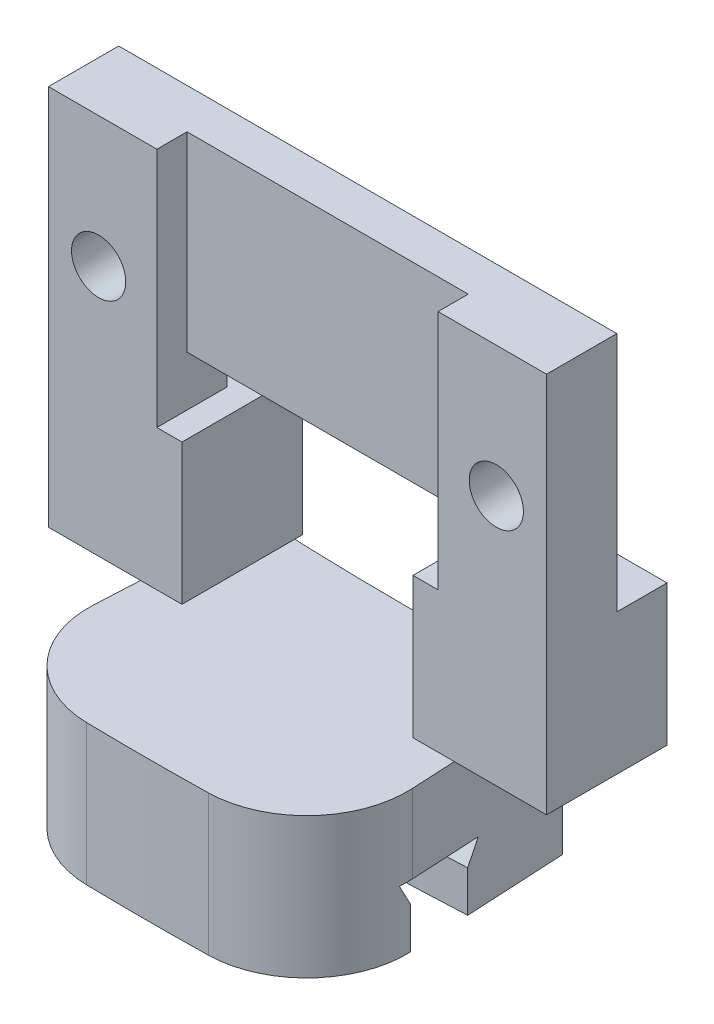
from build123d import *

# Parameters (mm, degrees)
MAIN_DEPTH            = 6
SKETCH8_R             = 1.35
HOLES_DEPTH           = 7
SKETCH12_W            = 14
SKETCH12_H            = 12
COMPONENTHOLES2_DEPTH = 1.5
SKETCH17_W            = 14
SKETCH17_H            = 2.5
HOLESCABLES_DEPTH     = 5.5
SKETCH16_W            = 2.5
SKETCH16_H            = 12
FIXEXTRUSION_DEPTH    = 25.8
SUPPORT_ANGLE         = 6
FILLET1_R             = 5


with BuildPart() as part:
    # Sketch7 → Main (new body)
    with BuildSketch(Plane.XY.offset(143)):
        Polygon((-12.4, 0), (-5.75, 0), (-5.75, 7), (5.75, 7), (5.75, 0), (12.4, 0), (12.4, 19), (-12.4, 19), align=None)
    extrude(amount=MAIN_DEPTH)

    # Sketch8 → Holes (cut, through all)
    with BuildSketch(Plane.XY.offset(149)):
        with Locations((-9.9, 12.5)):
            Circle(SKETCH8_R)
        with Locations((9.9, 12.5)):
            Circle(SKETCH8_R)
    extrude(amount=-HOLES_DEPTH, mode=Mode.SUBTRACT)

    # Sketch12 → ComponentHoles2 (cut)
    with BuildSketch(Plane.XY.offset(149)):
        with Locations((0, 13)):
            Rectangle(SKETCH12_W, SKETCH12_H)
    extrude(amount=-COMPONENTHOLES2_DEPTH, mode=Mode.SUBTRACT)

    # Sketch17 → HolesCables (cut, through all)
    with BuildSketch(Plane.XY.offset(147.5)):
        with Locations((0, 8.25)):
            Rectangle(SKETCH17_W, SKETCH17_H)
    extrude(amount=-HOLESCABLES_DEPTH, mode=Mode.SUBTRACT)

    # Sketch16 → FixExtrusion (cut, through all)
    with BuildSketch(Plane(origin=(12.4, 0, 0), x_dir=(0, 0, -1), z_dir=(1, 0, 0))):
        with Locations((-144.25, 13)):
            Rectangle(SKETCH16_W, SKETCH16_H)
    extrude(amount=-FIXEXTRUSION_DEPTH, mode=Mode.SUBTRACT)


with BuildPart() as body_2:
    # Sketch10 → Support (revolve, symmetric)
    with BuildSketch(Plane(origin=(0, 0, 0), x_dir=(0, 0, -1), z_dir=(1, 0, 0))) as support_sk:
        Polygon((-147.95, -3.9), (-152.05, -3.9), (-151.5, -4.95), (-151.5, -7), (-156.5, -7), (-156.5, 0), (-143.5, 0), (-143.5, -7), (-148.5, -7), (-148.5, -4.95), align=None)
    revolve(axis=Axis((0, 11, 0), (0, -1, 0)), revolution_arc=SUPPORT_ANGLE / 2)
    revolve(support_sk.sketch, axis=Axis((0, 11, 0), (0, 1, 0)), revolution_arc=SUPPORT_ANGLE / 2)

    # Fillet1
    fillet1_edges = [body_2.edges().sort_by_distance(p)[0] for p in [
        (8.190577152, -3.5, 156.285522189),
        (-8.190577152, -3.5, 156.285522189),
    ]]
    fillet(fillet1_edges, radius=FILLET1_R)


solid = Compound([part.part, body_2.part])
